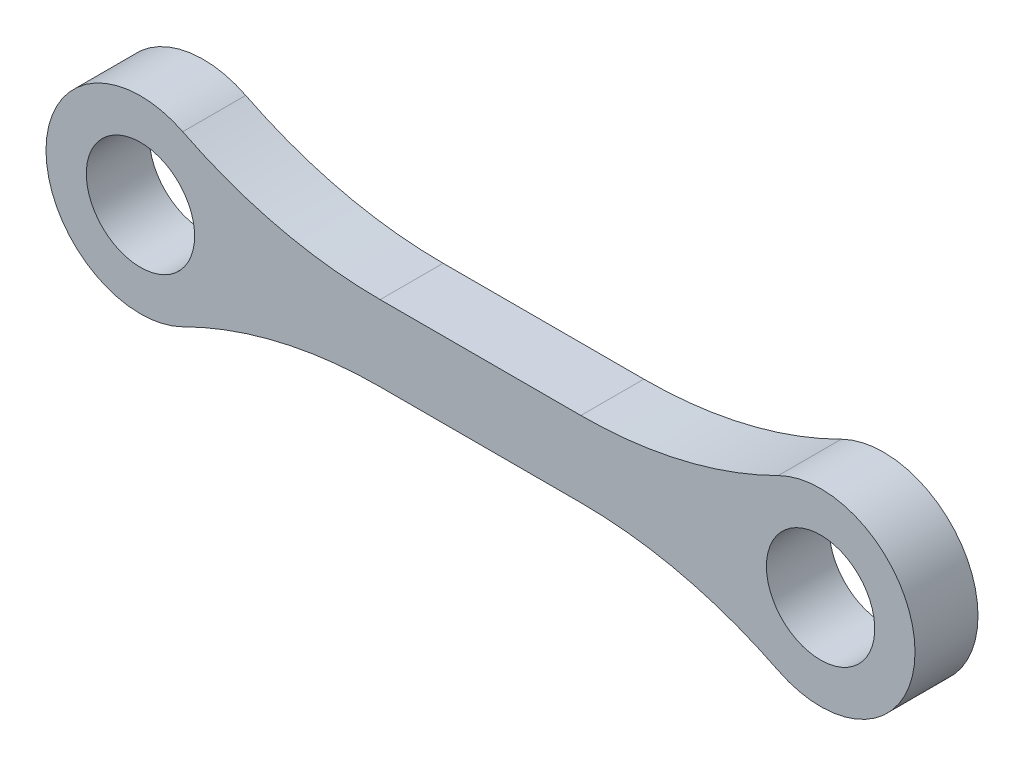
from build123d import *

# Parameters (mm, degrees)
CROQUIS1_R              = 4.3
SALIENTE_EXTRUIR1_DEPTH = 5


with BuildPart() as part:
    # Croquis1 → Saliente-Extruir1 (new body)
    with BuildSketch(Plane.XY):
        with BuildLine():
            Line((-7.967133689, 3), (7.967133689, 3))
            ThreePointArc((7.967133689, 3), (16.020266072, 3.939068439), (23.641258886, 6.705882353))
            ThreePointArc((23.641258886, 6.705882353), (34.5, 0), (23.641258886, -6.705882353))
            ThreePointArc((23.641258886, -6.705882353), (16.020266072, -3.939068439), (7.967133689, -3))
            Line((7.967133689, -3), (-7.967133689, -3))
            ThreePointArc((-7.967133689, -3), (-16.020266072, -3.939068439), (-23.641258886, -6.705882353))
            ThreePointArc((-23.641258886, -6.705882353), (-34.5, 0), (-23.641258886, 6.705882353))
            ThreePointArc((-23.641258886, 6.705882353), (-16.020266072, 3.939068439), (-7.967133689, 3))
        make_face()
        with Locations((-27, 0)):
            Circle(CROQUIS1_R, mode=Mode.SUBTRACT)
        with Locations((27, 0)):
            Circle(CROQUIS1_R, mode=Mode.SUBTRACT)
    extrude(amount=SALIENTE_EXTRUIR1_DEPTH)


solid = part.part
